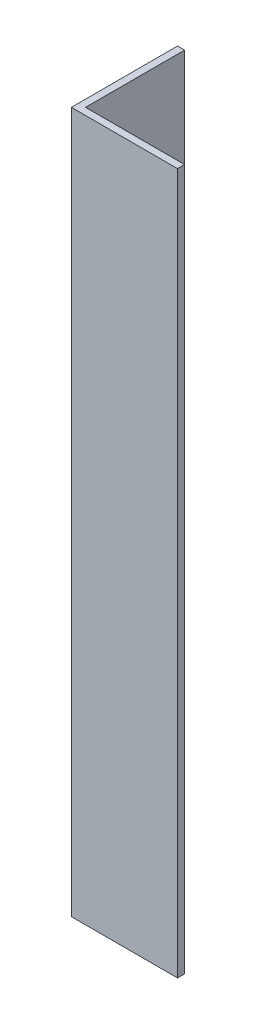
from build123d import *

# Parameters (mm, degrees)
EXTRUDE_1_DEPTH = 99


with BuildPart() as part:
    # Эскиз1 → Бобышка-Вытянуть1 (new body)
    with BuildSketch(Plane(origin=(0, 0, 0), x_dir=(1, 0, 0), z_dir=(0, 1, 0))):
        Polygon((0, 0), (0, 15), (1, 15), (1, 1), (15, 1), (15, 0), align=None)
    extrude(amount=EXTRUDE_1_DEPTH)


solid = part.part
